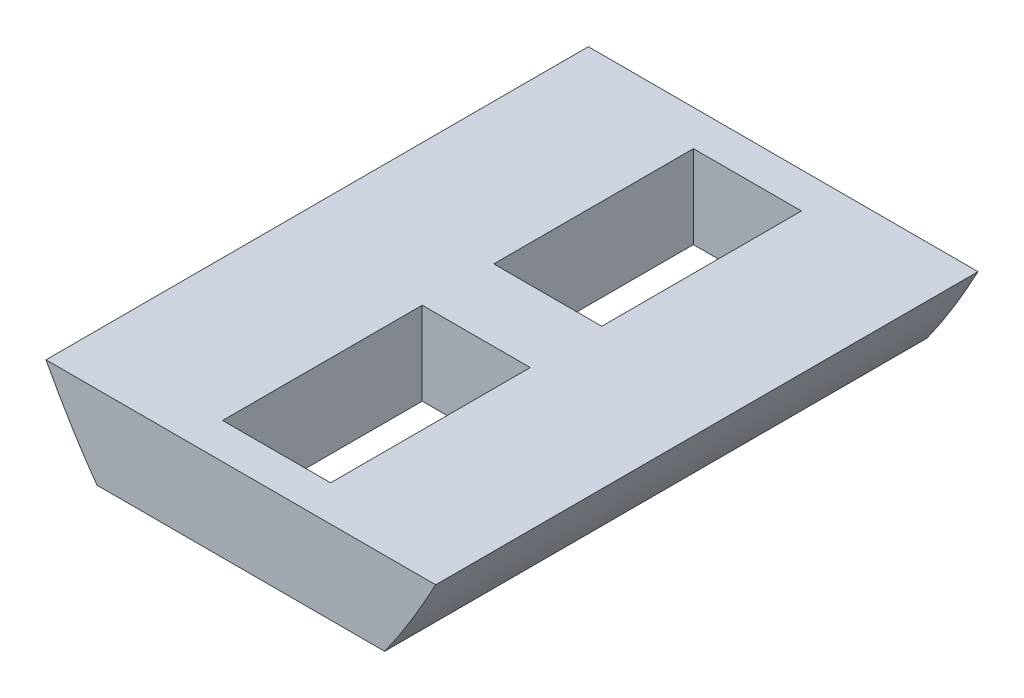
from build123d import *

# Parameters (mm, degrees)
BOSS_EXTRUDE2_DEPTH = 331.382
SKETCH3_W           = 66
SKETCH3_H           = 122
CUT_EXTRUDE2_DEPTH  = 128.0000001
SKETCH4_W           = 180
SKETCH4_H           = 60.8
CUT_EXTRUDE3_DEPTH  = 332.3820001
SKETCH5_W           = 260
SKETCH5_H           = 20
CUT_EXTRUDE4_DEPTH  = 332.3820001


with BuildPart() as part:
    # Sketch2 → Boss-Extrude2 (new body)
    with BuildSketch(Plane.XY):
        with BuildLine():
            Line((-127, 127), (127, 127))
            add(Edge.make_bspline(
                [(-127, 127), (0, -127), (127, 127)],
                knots=[0.056028396, 0.056028396, 0.056028396, 0.943971604, 0.943971604, 0.943971604], degree=2))
        make_face()
    extrude(amount=BOSS_EXTRUDE2_DEPTH)

    # Sketch3 → Cut-Extrude2 (cut, through all)
    with BuildSketch(Plane(origin=(0, 127, 0), x_dir=(1, 0, 0), z_dir=(0, 1, 0))):
        with Locations((0, -82.8455)):
            Rectangle(SKETCH3_W, SKETCH3_H)
        with Locations((0, -248.5365)):
            Rectangle(SKETCH3_W, SKETCH3_H)
    extrude(amount=-CUT_EXTRUDE2_DEPTH, mode=Mode.SUBTRACT)

    # Sketch4 → Cut-Extrude3 (cut, through all)
    with BuildSketch(Plane(origin=(0, 0, 0), x_dir=(-1, 0, 0), z_dir=(0, 0, -1))):
        with Locations((0, 30.4)):
            Rectangle(SKETCH4_W, SKETCH4_H)
    extrude(amount=-CUT_EXTRUDE3_DEPTH, mode=Mode.SUBTRACT)

    # Sketch5 → Cut-Extrude4 (cut, through all)
    with BuildSketch(Plane.XY.offset(331.382)):
        with Locations((0, 121.6)):
            Rectangle(SKETCH5_W, SKETCH5_H)
    extrude(amount=-CUT_EXTRUDE4_DEPTH, mode=Mode.SUBTRACT)


solid = part.part
